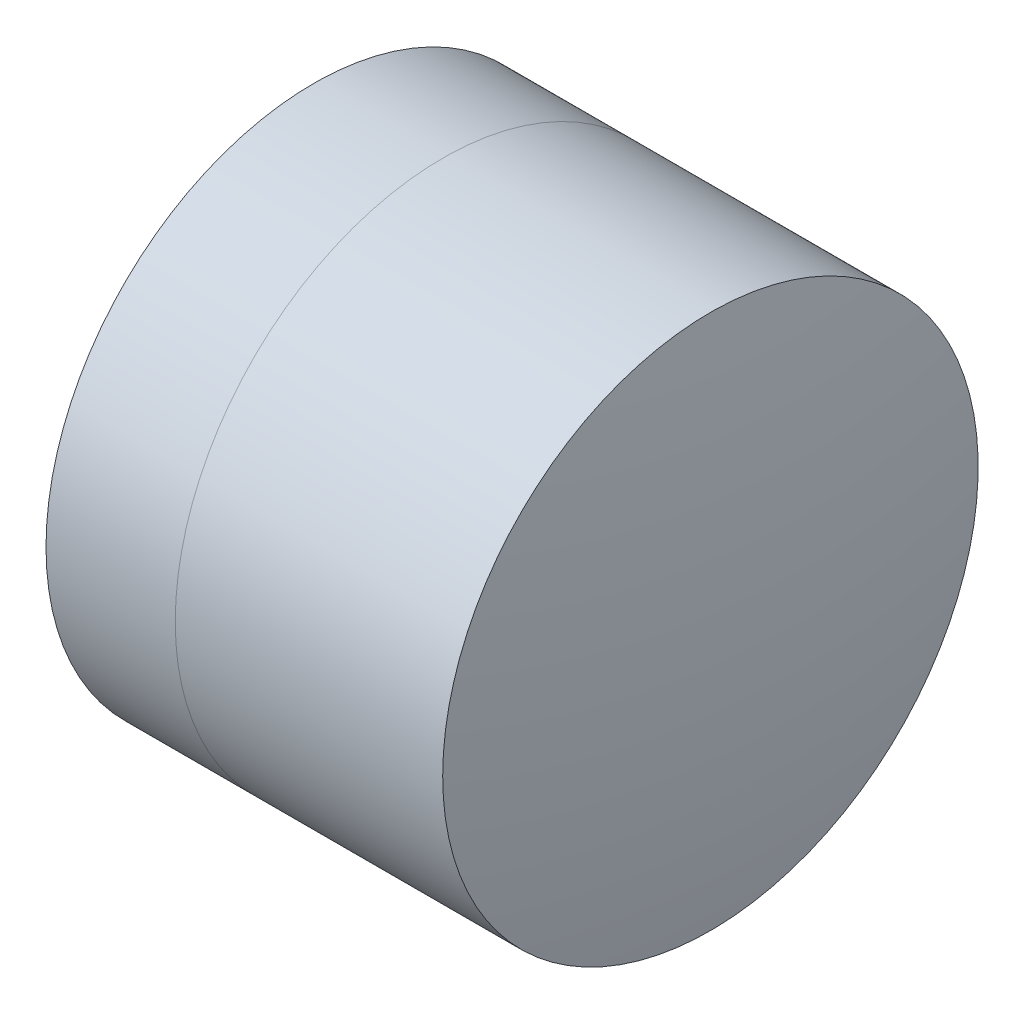
from build123d import *


with BuildPart() as part:
    # 草图1 one side → 旋转1 (revolve)
    with BuildSketch(Plane(origin=(0, 0, 0), x_dir=(1, 0, 0), z_dir=(0, 1, 0)), mode=Mode.PRIVATE) as revolve_1_sk:
        with BuildLine():
            ThreePointArc((2.470023111, 2.5), (2.102333618, 1.273957993), (1.978214333, 0))
            Line((1.978214333, 0), (4.478214333, 0))
            ThreePointArc((4.478214333, 0), (4.272958274, 1.312658393), (3.67678547, 2.5))
            Line((3.67678547, 2.5), (2.470023111, 2.5))
        make_face()
    revolve(revolve_1_sk.sketch.rotate(Axis((-0.816062176, 0, 0), (1, 0, 0)), 180), axis=Axis((-0.816062176, 0, 0), (1, 0, 0)))  # turned: the seam where the file's is


with BuildPart() as body_2:
    # 草图2 one side → 旋转3 (revolve)
    with BuildSketch(Plane(origin=(0, 0, 0), x_dir=(1, 0, 0), z_dir=(0, 1, 0)), mode=Mode.PRIVATE) as revolve_3_sk:
        with BuildLine():
            Line((6.173937416, 2.5), (3.67678547, 2.5))
            ThreePointArc((3.67678547, 2.5), (4.272958274, 1.312658393), (4.478214333, 0))
            Line((4.478214333, 0), (6.378214333, 0))
            ThreePointArc((6.378214333, 0), (6.327060144, 1.254165964), (6.173937416, 2.5))
        make_face()
    revolve(revolve_3_sk.sketch.rotate(Axis((-0.551919993, 0, 0), (1, 0, 0)), 180), axis=Axis((-0.551919993, 0, 0), (1, 0, 0)))  # turned: the seam where the file's is


solid = Compound([part.part, body_2.part])
